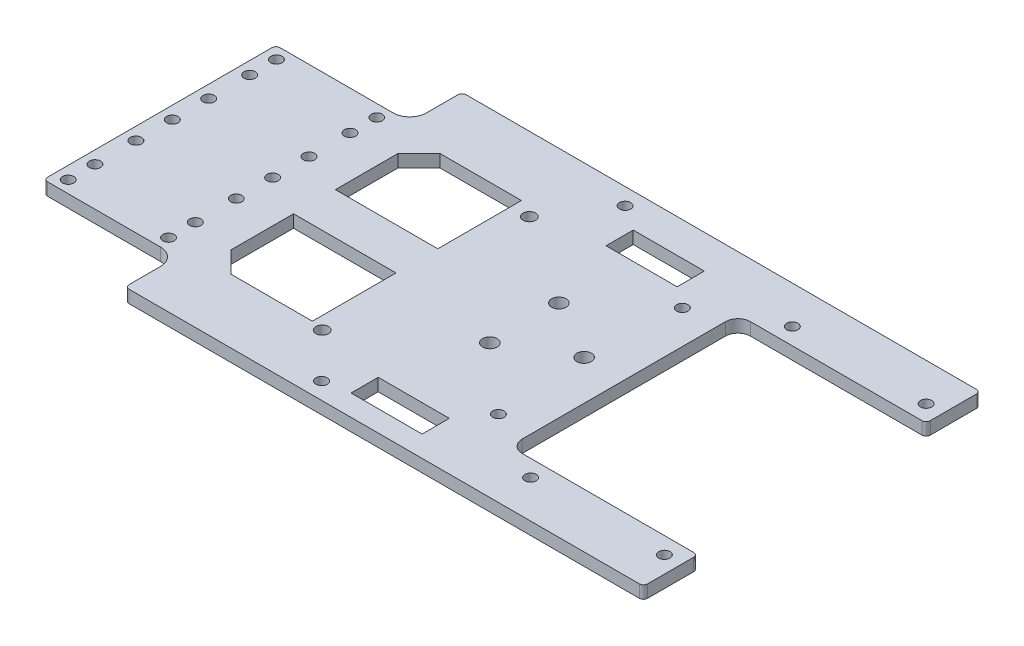
from build123d import *

# Parameters (mm, degrees)
BOSS_EXTRUDE1_DEPTH = 3
SKETCH2_R           = 1.35
CUT_EXTRUDE1_DEPTH  = 4
SKETCH4_R           = 1.35
CUT_EXTRUDE2_DEPTH  = 4
SKETCH5_R           = 1.35
CUT_EXTRUDE3_DEPTH  = 4
SKETCH6_R           = 1.35
CUT_EXTRUDE4_DEPTH  = 4
FILLET1_R           = 3
SKETCH7_R           = 1.75
CUT_EXTRUDE5_DEPTH  = 4
LPATTERN1_COUNT     = 2
LPATTERN1_PITCH     = 24
SKETCH8_R           = 1.35
CUT_EXTRUDE6_DEPTH  = 4
SKETCH9_R           = 1.5
CUT_EXTRUDE7_DEPTH  = 4
CUT_EXTRUDE8_DEPTH  = 4
FILLET2_R           = 1
FILLET3_R           = 4
SKETCH11_W          = 17
SKETCH11_H          = 6.5
CUT_EXTRUDE9_DEPTH  = 4


with BuildPart() as part:
    # Sketch1 → Boss-Extrude1 (new body)
    with BuildSketch(Plane(origin=(0, 0, 0), x_dir=(1, 0, 0), z_dir=(0, 1, 0))):
        Polygon((0, 27.8), (0, -27.8), (32, -27.8), (32, -40.3), (156, -40.3), (156, -27.3), (111, -27.3), (111, 27.3), (156, 27.3), (156, 40.3), (32, 40.3), (32, 27.8), align=None)
    extrude(amount=BOSS_EXTRUDE1_DEPTH)

    # Sketch2 → Cut-Extrude1 (cut, through all)
    with BuildSketch(Plane(origin=(0, 3, 0), x_dir=(1, 0, 0), z_dir=(0, 1, 0))):
        with Locations((3, 8.7)):
            Circle(SKETCH2_R)
        with Locations((3, 24.9)):
            Circle(SKETCH2_R)
        with Locations((3, -8.7)):
            Circle(SKETCH2_R)
        with Locations((3, -24.9)):
            Circle(SKETCH2_R)
    cut_extrude1 = extrude(amount=-CUT_EXTRUDE1_DEPTH, mode=Mode.SUBTRACT)

    # Sketch4 → Cut-Extrude2 (cut, through all)
    with BuildSketch(Plane(origin=(0, 3, 0), x_dir=(1, 0, 0), z_dir=(0, 1, 0))):
        with Locations((75, -36.3)):
            Circle(SKETCH4_R)
        with Locations((75, 36.3)):
            Circle(SKETCH4_R)
    extrude(amount=-CUT_EXTRUDE2_DEPTH, mode=Mode.SUBTRACT)

    # Sketch5 → Cut-Extrude3 (cut, through all)
    with BuildSketch(Plane(origin=(0, 3, 0), x_dir=(1, 0, 0), z_dir=(0, 1, 0))):
        with Locations((103, 22)):
            Circle(SKETCH5_R)
        with Locations((103, -22)):
            Circle(SKETCH5_R)
    extrude(amount=-CUT_EXTRUDE3_DEPTH, mode=Mode.SUBTRACT)

    # Sketch6 → Cut-Extrude4 (cut, through all)
    with BuildSketch(Plane(origin=(0, 3, 0), x_dir=(1, 0, 0), z_dir=(0, 1, 0))):
        with Locations((120, 31.3)):
            Circle(SKETCH6_R)
        with Locations((152, 31.3)):
            Circle(SKETCH6_R)
        with Locations((120, -31.3)):
            Circle(SKETCH6_R)
        with Locations((152, -31.3)):
            Circle(SKETCH6_R)
    extrude(amount=-CUT_EXTRUDE4_DEPTH, mode=Mode.SUBTRACT)

    # Fillet1
    fillet1_edges = [part.edges().sort_by_distance(p)[0] for p in [
        (111, 1.5, 27.3),
        (111, 1.5, -27.3),
    ]]
    fillet(fillet1_edges, radius=FILLET1_R)

    # Sketch7 → Cut-Extrude5 (cut, through all)
    with BuildSketch(Plane(origin=(0, 3, 0), x_dir=(1, 0, 0), z_dir=(0, 1, 0))):
        with Locations((101.5, 0)):
            Circle(SKETCH7_R)
        with Locations((87.210580838, 8.25)):
            Circle(SKETCH7_R)
        with Locations((87.210580838, -8.25)):
            Circle(SKETCH7_R)
    extrude(amount=-CUT_EXTRUDE5_DEPTH, mode=Mode.SUBTRACT)

    # LPattern1: Cut-Extrude1 ×2
    with Locations(*[(i * LPATTERN1_PITCH, 0, 0) for i in range(1, LPATTERN1_COUNT)]):
        add(cut_extrude1, mode=Mode.SUBTRACT)

    # Sketch8 → Cut-Extrude6 (cut, through all)
    with BuildSketch(Plane(origin=(0, 3, 0), x_dir=(1, 0, 0), z_dir=(0, 1, 0))):
        with Locations((3, 18.5)):
            Circle(SKETCH8_R)
        with Locations((27, 18.5)):
            Circle(SKETCH8_R)
        with Locations((3, -18.5)):
            Circle(SKETCH8_R)
        with Locations((27, -18.5)):
            Circle(SKETCH8_R)
        with Locations((3, 0)):
            Circle(SKETCH8_R)
        with Locations((27, 0)):
            Circle(SKETCH8_R)
    extrude(amount=-CUT_EXTRUDE6_DEPTH, mode=Mode.SUBTRACT)

    # Sketch9 → Cut-Extrude7 (cut, through all)
    with BuildSketch(Plane(origin=(0, 3, 0), x_dir=(1, 0, 0), z_dir=(0, 1, 0))):
        with Locations((65.8, 22.6)):
            Circle(SKETCH9_R)
        with Locations((64.53, -25.66)):
            Circle(SKETCH9_R)
    extrude(amount=-CUT_EXTRUDE7_DEPTH, mode=Mode.SUBTRACT)

    # Sketch10 → Cut-Extrude8 (cut, through all)
    with BuildSketch(Plane(origin=(0, 3, 0), x_dir=(1, 0, 0), z_dir=(0, 1, 0))):
        Polygon((37, 5), (61.5, 5), (61.5, 25), (42, 25), (37, 20), align=None)
        Polygon((37, -5), (61.5, -5), (61.5, -25), (42, -25), (37, -20), align=None)
    extrude(amount=-CUT_EXTRUDE8_DEPTH, mode=Mode.SUBTRACT)

    # Fillet2
    fillet2_edges = [part.edges().sort_by_distance(p)[0] for p in [
        (0, 1.5, -27.8),
        (0, 1.5, 27.8),
        (32, 1.5, 40.3),
        (156, 1.5, 40.3),
        (156, 1.5, 27.3),
        (156, 1.5, -27.3),
        (156, 1.5, -40.3),
        (32, 1.5, -40.3),
    ]]
    fillet(fillet2_edges, radius=FILLET2_R)

    # Fillet3
    fillet3_edges = [part.edges().sort_by_distance(p)[0] for p in [
        (32, 1.5, 27.8),
        (32, 1.5, -27.8),
    ]]
    fillet(fillet3_edges, radius=FILLET3_R)

    # Sketch11 → Cut-Extrude9 (cut, through all)
    with BuildSketch(Plane(origin=(0, 3, 0), x_dir=(1, 0, 0), z_dir=(0, 1, 0))):
        with Locations((89.5, 29)):
            Rectangle(SKETCH11_W, SKETCH11_H)
        with Locations((89.5, -32)):
            Rectangle(SKETCH11_W, SKETCH11_H)
    extrude(amount=-CUT_EXTRUDE9_DEPTH, mode=Mode.SUBTRACT)


solid = part.part
